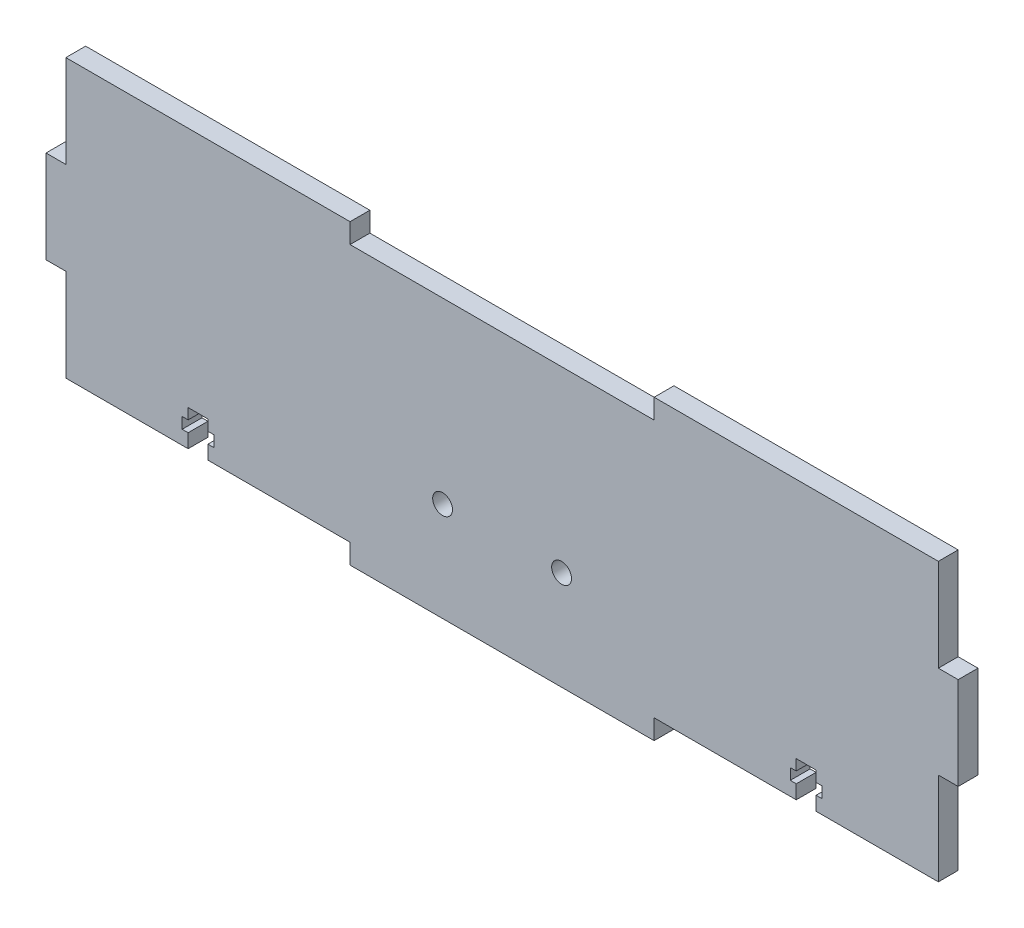
from build123d import *

# Parameters (mm, degrees)
SALIENTE_EXTRUIR1_DEPTH = 5
CORTAR_EXTRUIR1_DEPTH   = 5
CROQUIS3_W              = 76.666666666
CROQUIS3_H              = 5
CORTAR_EXTRUIR2_DEPTH   = 10
CROQUIS4_R              = 2.5
CORTAR_EXTRUIR3_DEPTH   = 10


with BuildPart() as part:
    # Croquis1 → Saliente-Extruir1 (new body)
    with BuildSketch(Plane.XY):
        Polygon((76.666666667, 5), (76.666666667, 0), (153.333333333, 0), (153.333333333, 5), (225, 5), (225, 28.333333333), (230, 28.333333333), (230, 51.666666667), (225, 51.666666667), (225, 75), (5, 75), (5, 51.666666667), (0, 51.666666667), (0, 28.333333333), (5, 28.333333333), (5, 5), align=None)
    extrude(amount=SALIENTE_EXTRUIR1_DEPTH)

    # Croquis2 → Cortar-Extruir1 (cut)
    with BuildSketch(Plane.XY.offset(5)):
        Polygon((35.833333333, 5), (35.833333333, 8.5), (34.333333333, 8.5), (34.333333333, 11.3), (35.833333333, 11.3), (35.833333333, 14), (40.833333333, 14), (40.833333333, 11.3), (42.333333333, 11.3), (42.333333333, 8.5), (40.833333333, 8.5), (40.833333333, 5), align=None)
        Polygon((189.166666667, 5), (189.166666667, 8.5), (187.666666667, 8.5), (187.666666667, 11.3), (189.166666667, 11.3), (189.166666667, 14), (194.166666667, 14), (194.166666667, 11.3), (195.666666667, 11.3), (195.666666667, 8.5), (194.166666667, 8.5), (194.166666667, 5), align=None)
    extrude(amount=-CORTAR_EXTRUIR1_DEPTH, mode=Mode.SUBTRACT)

    # Croquis3 → Cortar-Extruir2 (cut)
    with BuildSketch(Plane.XY.offset(5)):
        with Locations((115, 72.5)):
            Rectangle(CROQUIS3_W, CROQUIS3_H)
    extrude(amount=-CORTAR_EXTRUIR2_DEPTH, mode=Mode.SUBTRACT)

    # Croquis4 → Cortar-Extruir3 (cut)
    with BuildSketch(Plane.XY.offset(5)):
        with Locations((100, 25)):
            Circle(CROQUIS4_R)
        with Locations((130, 25)):
            Circle(CROQUIS4_R)
    extrude(amount=-CORTAR_EXTRUIR3_DEPTH, mode=Mode.SUBTRACT)


solid = part.part
